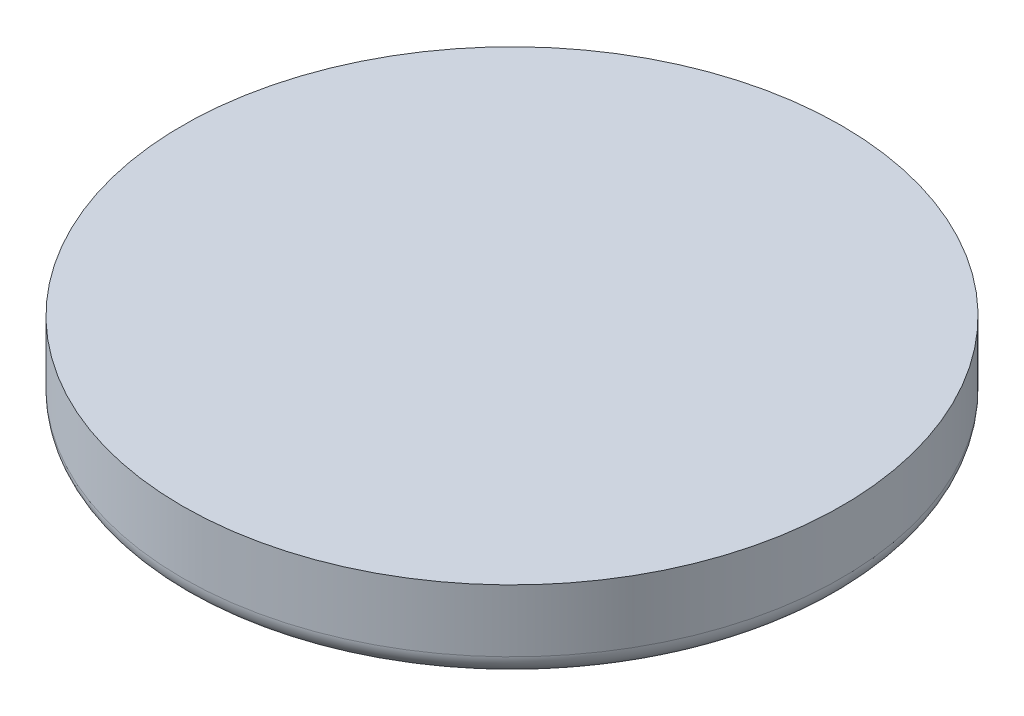
from build123d import *

# Parameters (mm, degrees)
SKETCH1_R           = 3.175
BOSS_EXTRUDE1_DEPTH = 0.8
FILLET3_R           = 0.2


with BuildPart() as part:
    # Sketch1 → Boss-Extrude1 (new body)
    with BuildSketch(Plane(origin=(0, 0, 0), x_dir=(1, 0, 0), z_dir=(0, 1, 0))):
        Circle(SKETCH1_R)
    extrude(amount=BOSS_EXTRUDE1_DEPTH)

    # Fillet3
    fillet3_edges = [part.edges().sort_by_distance(p)[0] for p in [
        (-3.175, 0, 0),
    ]]
    fillet(fillet3_edges, radius=FILLET3_R)


solid = part.part
